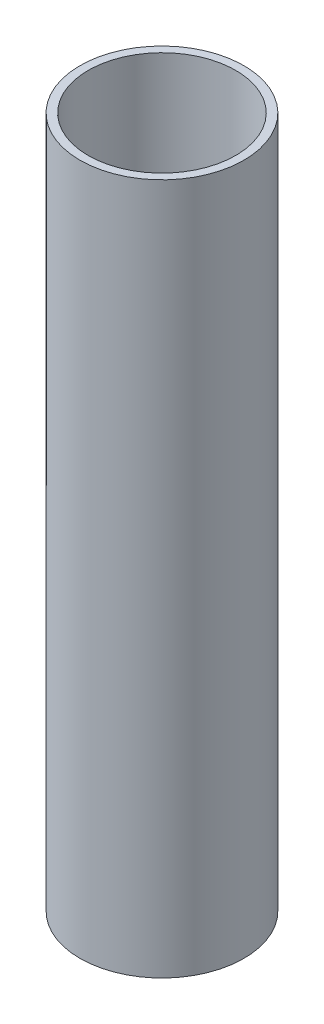
from build123d import *

# Parameters (mm, degrees)
SKETCH1_R           = 30
BOSS_EXTRUDE1_DEPTH = 3
SKETCH2_R           = 30
SKETCH2_R_2         = 27
BOSS_EXTRUDE2_DEPTH = 250
CUT_EXTRUDE1_DEPTH  = 44


with BuildPart() as part:
    # Sketch1 → Boss-Extrude1 (new body)
    with BuildSketch(Plane(origin=(0, 0, 0), x_dir=(1, 0, 0), z_dir=(0, 1, 0))):
        Circle(SKETCH1_R)
    extrude(amount=BOSS_EXTRUDE1_DEPTH)

    # Sketch2 → Boss-Extrude2 (add)
    with BuildSketch(Plane(origin=(0, 3, 0), x_dir=(1, 0, 0), z_dir=(0, 1, 0))):
        Circle(SKETCH2_R)
        Circle(SKETCH2_R_2, mode=Mode.SUBTRACT)
    extrude(amount=BOSS_EXTRUDE2_DEPTH)

    # Sketch3 → Cut-Extrude1 (cut)
    with BuildSketch(Plane.XZ):
        Polygon((-1.5, 0), (-1.5, 12.25), (1.5, 12.25), (1.5, 0), (1.5, -12.25), (-1.5, -12.25), align=None)
    extrude(amount=-CUT_EXTRUDE1_DEPTH, mode=Mode.SUBTRACT)


solid = part.part
